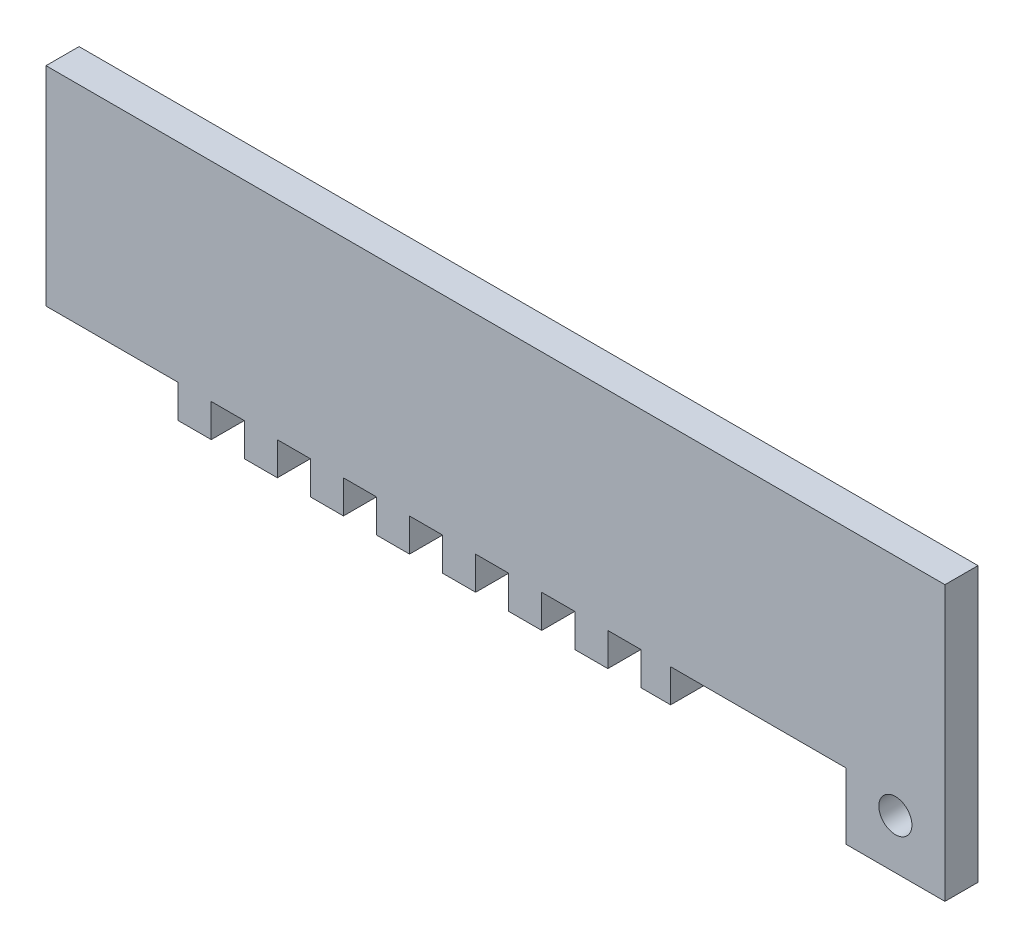
from build123d import *

# Parameters (mm, degrees)
ESQUISSE1_W                = 189
ESQUISSE1_H                = 73
BOSS_EXTRU_1_DEPTH         = 10
ESQUISSE2_W                = 10
ESQUISSE2_H                = 10
ENL_V_MAT_EXTRU_2_DEPTH    = 10
R_P_TITION_LIN_AIRE2_COUNT = 8
R_P_TITION_LIN_AIRE2_PITCH = 20
ESQUISSE3_W                = 30
ESQUISSE3_H                = 10
ENL_V_MAT_EXTRU_3_DEPTH    = 10
ESQUISSE4_W                = 10
ESQUISSE4_H                = 63
BOSS_EXTRU_2_DEPTH         = 83
ESQUISSE5_W                = 30
ESQUISSE5_H                = 10
BOSS_EXTRU_3_DEPTH         = 20
ESQUISSE6_R                = 5
ENL_V_MAT_EXTRU_4_DEPTH    = 10


with BuildPart() as part:
    # Esquisse1 → Boss.-Extru.1 (new body)
    with BuildSketch(Plane.XY):
        with Locations((-94.5, 36.5)):
            Rectangle(ESQUISSE1_W, ESQUISSE1_H)
    extrude(amount=BOSS_EXTRU_1_DEPTH)

    # Esquisse2 → Enlèv. mat.-Extru.2 (cut)
    with BuildSketch(Plane.XY.offset(10)):
        with Locations((-154, 5)):
            Rectangle(ESQUISSE2_W, ESQUISSE2_H)
    enl_v_mat_extru_2 = extrude(amount=-ENL_V_MAT_EXTRU_2_DEPTH, mode=Mode.SUBTRACT)

    # Répétition linéaire2: Enlèv. mat.-Extru.2 ×8
    with Locations(*[(i * R_P_TITION_LIN_AIRE2_PITCH, 0, 0) for i in range(1, R_P_TITION_LIN_AIRE2_COUNT)]):
        add(enl_v_mat_extru_2, mode=Mode.SUBTRACT)

    # Esquisse3 → Enlèv. mat.-Extru.3 (cut)
    with BuildSketch(Plane.XY.offset(10)):
        with Locations((-174, 5)):
            Rectangle(ESQUISSE3_W, ESQUISSE3_H)
    extrude(amount=-ENL_V_MAT_EXTRU_3_DEPTH, mode=Mode.SUBTRACT)

    # Esquisse4 → Boss.-Extru.2 (add)
    with BuildSketch(Plane(origin=(0, 0, 0), x_dir=(0, 0, -1), z_dir=(1, 0, 0))):
        with Locations((-5, 41.5)):
            Rectangle(ESQUISSE4_W, ESQUISSE4_H)
    extrude(amount=BOSS_EXTRU_2_DEPTH)

    # Esquisse5 → Boss.-Extru.3 (add)
    with BuildSketch(Plane.XZ.offset(-10)):
        with Locations((68, 5)):
            Rectangle(ESQUISSE5_W, ESQUISSE5_H)
    extrude(amount=BOSS_EXTRU_3_DEPTH)

    # Esquisse6 → Enlèv. mat.-Extru.4 (cut)
    with BuildSketch(Plane.XY.offset(10)):
        with Locations((68, 5)):
            Circle(ESQUISSE6_R)
    extrude(amount=-ENL_V_MAT_EXTRU_4_DEPTH, mode=Mode.SUBTRACT)


solid = part.part
